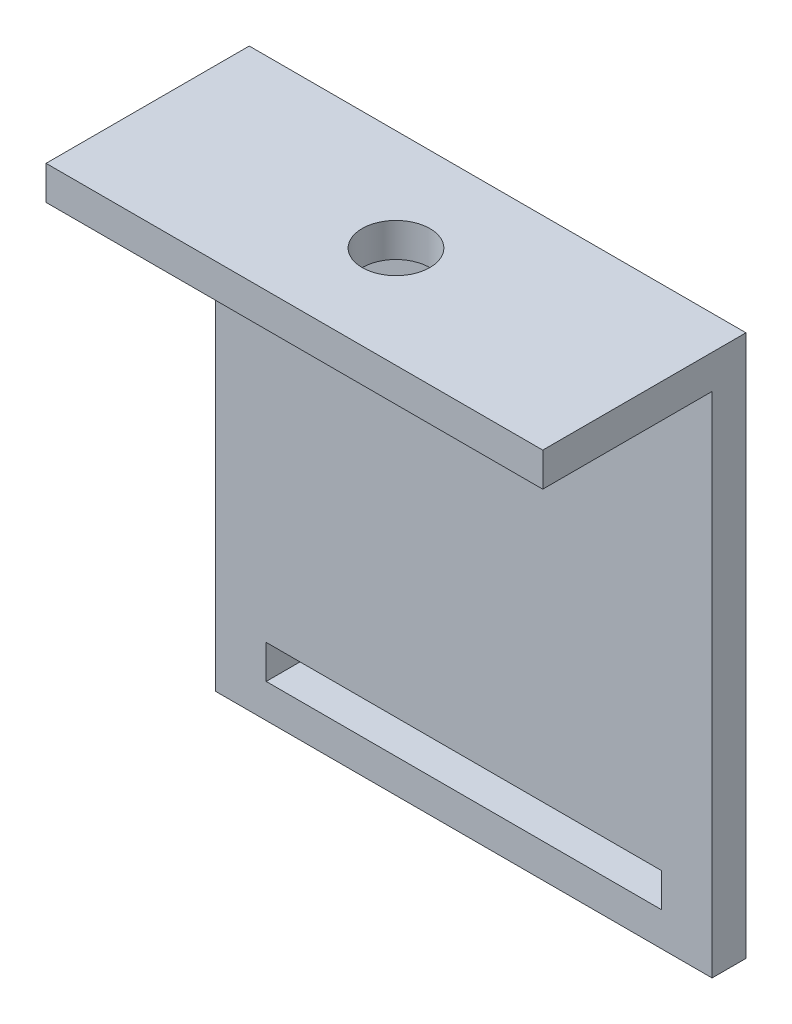
from build123d import *

# Parameters (mm, degrees)
ESTRUSIONE_ESTRUSIONE6_DEPTH = 44
SCHIZZO9_W                   = 35
SCHIZZO9_H                   = 3
TAGLIO_ESTRUSIONE2_DEPTH     = 44
SCHIZZO10_R                  = 3
TAGLIO_ESTRUSIONE3_DEPTH     = 10


with BuildPart() as part:
    # Schizzo8 → Estrusione-Estrusione6 (new body)
    with BuildSketch(Plane(origin=(0, 0, 0), x_dir=(0, 0, -1), z_dir=(1, 0, 0))):
        Polygon((0, 0), (0, 3), (18, 3), (18, -45), (15, -45), (15, 0), align=None)
    extrude(amount=ESTRUSIONE_ESTRUSIONE6_DEPTH)

    # Schizzo9 → Taglio-Estrusione2 (cut)
    with BuildSketch(Plane.XY.offset(-15)):
        with Locations((22, -40.5)):
            Rectangle(SCHIZZO9_W, SCHIZZO9_H)
    extrude(amount=-TAGLIO_ESTRUSIONE2_DEPTH, mode=Mode.SUBTRACT)

    # Schizzo10 → Taglio-Estrusione3 (cut)
    with BuildSketch(Plane(origin=(0, 3, 0), x_dir=(1, 0, 0), z_dir=(0, 1, 0))):
        with Locations((22, 9)):
            Circle(SCHIZZO10_R)
    extrude(amount=-TAGLIO_ESTRUSIONE3_DEPTH, mode=Mode.SUBTRACT)


solid = part.part
